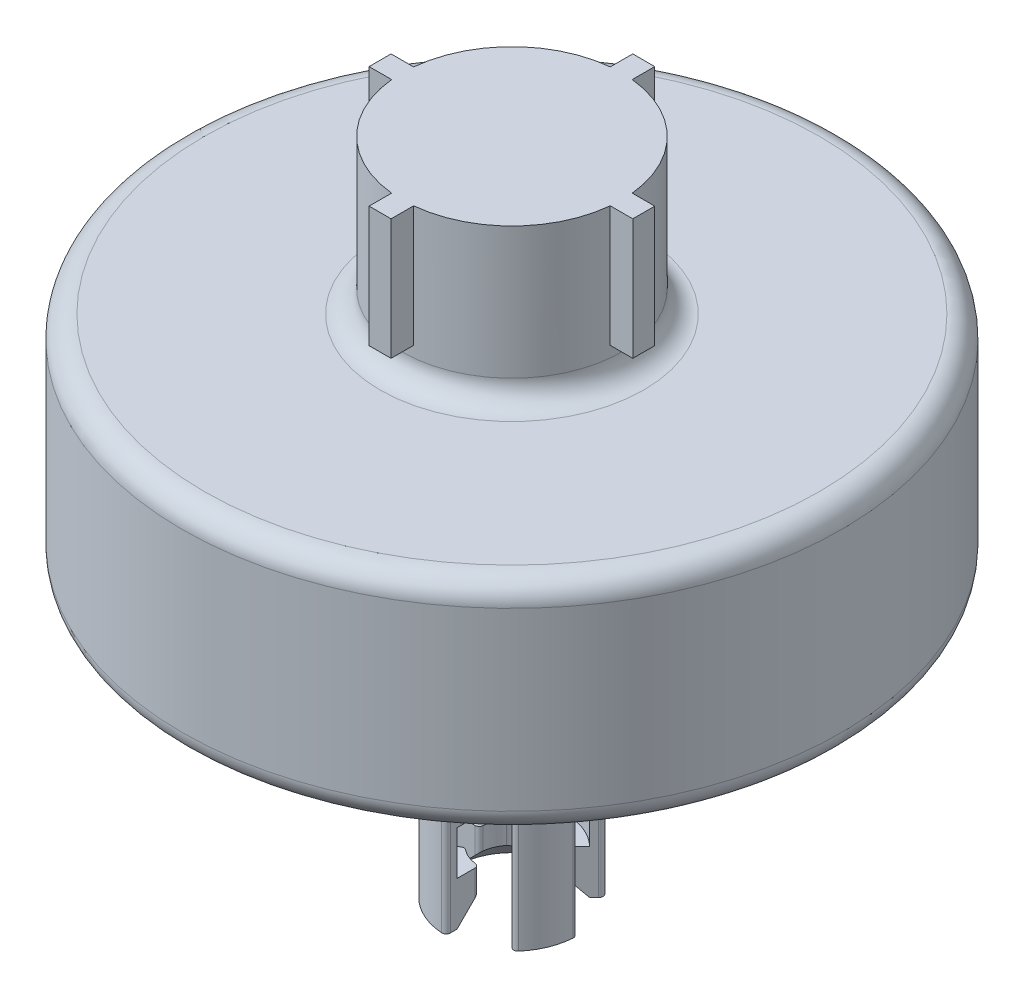
from build123d import *

# Parameters (mm, degrees)
SKETCH1_R           = 150
BOSS_EXTRUDE2_DEPTH = 100
SKETCH2_R           = 50
BOSS_EXTRUDE3_DEPTH = 70
SKETCH3_W           = 10
SKETCH3_H           = 55
BOSS_EXTRUDE4_DEPTH = 60
CIRPATTERN1_COUNT   = 4
SKETCH4_R           = 50
BOSS_EXTRUDE5_DEPTH = 50
SKETCH5_R           = 30
BOSS_EXTRUDE6_DEPTH = 80
CUT_EXTRUDE2_DEPTH  = 80
SKETCH7_R           = 25
CUT_EXTRUDE3_DEPTH  = 20
SKETCH8_R           = 25
CUT_EXTRUDE4_DEPTH  = 39
CUT_EXTRUDE4_DRAFT  = -45
FILLET1_R           = 10
FILLET2_R           = 10
FILLET3_R           = 10
FILLET4_R           = 10


with BuildPart() as part:
    # Sketch1 → Boss-Extrude2 (new body)
    with BuildSketch(Plane(origin=(0, 0, 0), x_dir=(1, 0, 0), z_dir=(0, 1, 0))):
        Circle(SKETCH1_R)
    extrude(amount=BOSS_EXTRUDE2_DEPTH)

    # Sketch2 → Boss-Extrude3 (add)
    with BuildSketch(Plane(origin=(0, 100, 0), x_dir=(1, 0, 0), z_dir=(0, 1, 0))):
        Circle(SKETCH2_R)
    extrude(amount=BOSS_EXTRUDE3_DEPTH)

    # Sketch3 → Boss-Extrude4 (add)
    with BuildSketch(Plane.XY):
        with Locations((0, 142.5)):
            Rectangle(SKETCH3_W, SKETCH3_H)
    boss_extrude4 = extrude(amount=BOSS_EXTRUDE4_DEPTH)

    # CirPattern1: Boss-Extrude4 ×4 about axis
    cirpattern1_axis = Axis((0, 0, 0), (0, 1, 0))
    for i in range(1, CIRPATTERN1_COUNT):
        add(boss_extrude4.rotate(cirpattern1_axis, i * 360 / CIRPATTERN1_COUNT))

    # Sketch4 → Boss-Extrude5 (add)
    with BuildSketch(Plane.XZ):
        Circle(SKETCH4_R)
    extrude(amount=BOSS_EXTRUDE5_DEPTH)

    # Sketch5 → Boss-Extrude6 (add)
    with BuildSketch(Plane.XZ.offset(50)):
        Circle(SKETCH5_R)
    extrude(amount=BOSS_EXTRUDE6_DEPTH)

    # Sketch6 → Cut-Extrude2 (cut)
    with BuildSketch(Plane.XZ.offset(130)):
        with BuildLine():
            Line((0, 16.881943016), (0, 27.928480088))
            ThreePointArc((0, 27.928480088), (-0.637229712, 29.392330197), (-2.142857143, 29.923371522))
            ThreePointArc((-2.142857143, 29.923371522), (11.480502971, 27.716385975), (22.674247736, 19.643790103))
            ThreePointArc((22.674247736, 19.643790103), (21.234105448, 20.332926546), (19.748417658, 19.748417658))
            Line((19.748417658, 19.748417658), (11.937336386, 11.937336386))
            ThreePointArc((11.937336386, 11.937336386), (11.355025232, 10.640974667), (11.780779366, 9.285108374))
            ThreePointArc((11.780779366, 9.285108374), (13.858192988, 5.740251485), (14.895832073, 1.764705882))
            ThreePointArc((14.895832073, 1.764705882), (15.553520688, 0.504909997), (16.881943016, 0))
            Line((16.881943016, 0), (27.928480088, 0))
            ThreePointArc((27.928480088, 0), (29.392330197, 0.637229712), (29.923371522, 2.142857143))
            ThreePointArc((29.923371522, 2.142857143), (27.716385975, -11.480502971), (19.643790103, -22.674247736))
            ThreePointArc((19.643790103, -22.674247736), (20.332926546, -21.234105448), (19.748417658, -19.748417658))
            Line((19.748417658, -19.748417658), (11.937336386, -11.937336386))
            ThreePointArc((11.937336386, -11.937336386), (10.640974667, -11.355025232), (9.285108374, -11.780779366))
            ThreePointArc((9.285108374, -11.780779366), (5.740251485, -13.858192988), (1.764705882, -14.895832073))
            ThreePointArc((1.764705882, -14.895832073), (0.504909997, -15.553520688), (0, -16.881943016))
            Line((0, -16.881943016), (0, -27.928480088))
            ThreePointArc((0, -27.928480088), (0.637229712, -29.392330197), (2.142857143, -29.923371522))
            ThreePointArc((2.142857143, -29.923371522), (-11.480502971, -27.716385975), (-22.674247736, -19.643790103))
            ThreePointArc((-22.674247736, -19.643790103), (-21.234105448, -20.332926546), (-19.748417658, -19.748417658))
            Line((-19.748417658, -19.748417658), (-11.937336386, -11.937336386))
            ThreePointArc((-11.937336386, -11.937336386), (-11.355025232, -10.640974667), (-11.780779366, -9.285108374))
            ThreePointArc((-11.780779366, -9.285108374), (-13.858192988, -5.740251485), (-14.895832073, -1.764705882))
            ThreePointArc((-14.895832073, -1.764705882), (-15.553520688, -0.504909997), (-16.881943016, 0))
            Line((-16.881943016, 0), (-27.928480088, 0))
            ThreePointArc((-27.928480088, 0), (-29.392330197, -0.637229712), (-29.923371522, -2.142857143))
            ThreePointArc((-29.923371522, -2.142857143), (-27.716385975, 11.480502971), (-19.643790103, 22.674247736))
            ThreePointArc((-19.643790103, 22.674247736), (-20.332926546, 21.234105448), (-19.748417658, 19.748417658))
            Line((-19.748417658, 19.748417658), (-11.937336386, 11.937336386))
            ThreePointArc((-11.937336386, 11.937336386), (-10.640974667, 11.355025232), (-9.285108374, 11.780779366))
            ThreePointArc((-9.285108374, 11.780779366), (-5.740251485, 13.858192988), (-1.764705882, 14.895832073))
            ThreePointArc((-1.764705882, 14.895832073), (-0.504909997, 15.553520688), (0, 16.881943016))
        make_face()
    extrude(amount=-CUT_EXTRUDE2_DEPTH, mode=Mode.SUBTRACT)

    # Sketch7 → Cut-Extrude3 (cut)
    with BuildSketch(Plane(origin=(0, -110, 0), x_dir=(-1, 0, 0), z_dir=(0, -1, 0))):
        Circle(SKETCH7_R)
    extrude(amount=-CUT_EXTRUDE3_DEPTH, mode=Mode.SUBTRACT)


with BuildPart() as cut_extrude4_tool:
    # Sketch8 → Cut-Extrude4 (with draft: the straight prism first)
    with BuildSketch(Plane.XZ.offset(130)):
        Circle(SKETCH8_R)
    extrude(amount=-CUT_EXTRUDE4_DEPTH)
    # Cut-Extrude4: the draft: its side faces are tilted about the plane it starts from
    cut_extrude4_sides = [cut_extrude4_tool.faces().sort_by_distance(p)[0] for p in [
        (-25, -110.5, 0),
    ]]
    draft(cut_extrude4_sides, Plane.XZ.offset(130), CUT_EXTRUDE4_DRAFT)


with BuildPart() as part_1:
    add(part.part)

    # Cut-Extrude4: cut by cut_extrude4_tool
    add(cut_extrude4_tool.part, mode=Mode.SUBTRACT)

    # Fillet1
    fillet1_edges = [part_1.edges().sort_by_distance(p)[0] for p in [
        (-150, 0, 0),
        (-150, 100, 0),
    ]]
    fillet(fillet1_edges, radius=FILLET1_R)

    # Fillet2
    fillet2_edges = [part_1.edges().sort_by_distance(p)[0] for p in [
        (-50, -50, 0),
    ]]
    fillet(fillet2_edges, radius=FILLET2_R)

    # Fillet3
    fillet3_edges = [part_1.edges().sort_by_distance(p)[0] for p in [
        (-50, 0, 0),
    ]]
    fillet(fillet3_edges, radius=FILLET3_R)

    # Fillet4
    fillet4_edges = [part_1.edges().sort_by_distance(p)[0] for p in [
        (-50, 100, 0),
    ]]
    fillet(fillet4_edges, radius=FILLET4_R)


solid = part_1.part
